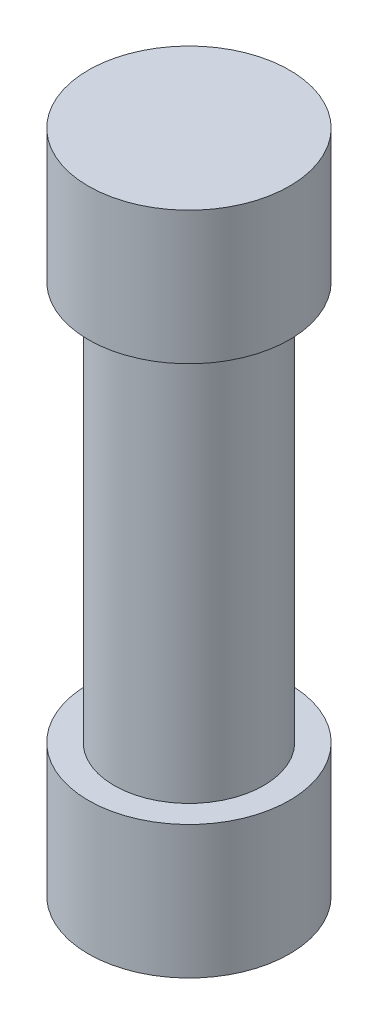
from build123d import *

# Parameters (mm, degrees)
SKETCH1_R           = 3.025
BOSS_EXTRUDE1_DEPTH = 4
SKETCH2_R           = 2.25
BOSS_EXTRUDE2_DEPTH = 12
SKETCH3_R           = 3.025
BOSS_EXTRUDE3_DEPTH = 4


with BuildPart() as part:
    # Sketch1 → Boss-Extrude1 (new body)
    with BuildSketch(Plane(origin=(0, 0, 0), x_dir=(1, 0, 0), z_dir=(0, 1, 0))):
        Circle(SKETCH1_R)
    extrude(amount=BOSS_EXTRUDE1_DEPTH)

    # Sketch2 → Boss-Extrude2 (add)
    with BuildSketch(Plane(origin=(0, 4, 0), x_dir=(1, 0, 0), z_dir=(0, 1, 0))):
        Circle(SKETCH2_R)
    extrude(amount=BOSS_EXTRUDE2_DEPTH)

    # Sketch3 → Boss-Extrude3 (add)
    with BuildSketch(Plane(origin=(0, 16, 0), x_dir=(1, 0, 0), z_dir=(0, 1, 0))):
        Circle(SKETCH3_R)
    extrude(amount=BOSS_EXTRUDE3_DEPTH)


solid = part.part
